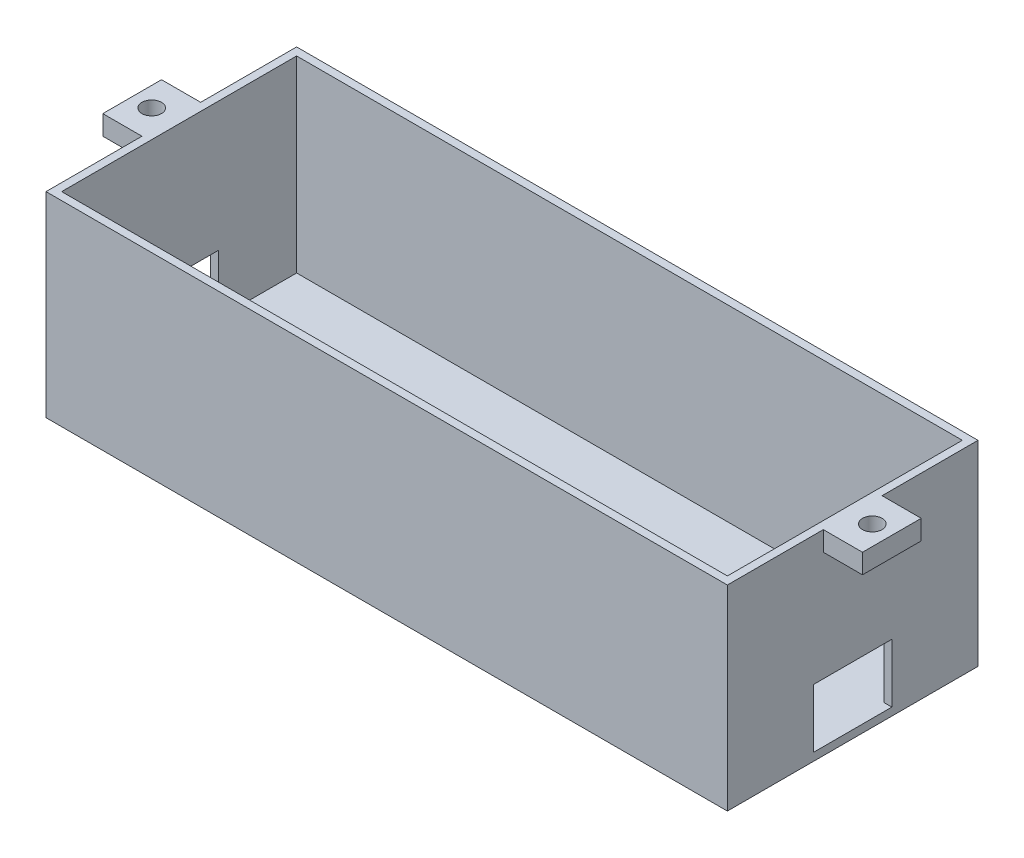
from build123d import *

# Parameters (mm, degrees)
SKETCH1_W           = 174
SKETCH1_H           = 64
SKETCH1_W_2         = 170
SKETCH1_H_2         = 60
BOSS_EXTRUDE1_DEPTH = 25
SKETCH2_W           = 174
SKETCH2_H           = 2
BOSS_EXTRUDE2_DEPTH = 64
SKETCH9_W           = 10
SKETCH9_H           = 15
SKETCH9_R           = 2.5
BOSS_EXTRUDE3_DEPTH = 5
SKETCH10_W          = 20
SKETCH10_H          = 15
CUT_EXTRUDE2_DEPTH  = 174
CUT_EXTRUDE3_REACH  = 4
SKETCH11_R          = 2.5
SKETCH11_R_2        = 1.25


with BuildPart() as part:
    # Sketch1 → Boss-Extrude1 (new body, symmetric)
    with BuildSketch(Plane(origin=(0, 0, 0), x_dir=(1, 0, 0), z_dir=(0, 1, 0))):
        Rectangle(SKETCH1_W, SKETCH1_H)
        Rectangle(SKETCH1_W_2, SKETCH1_H_2, mode=Mode.SUBTRACT)
    extrude(amount=BOSS_EXTRUDE1_DEPTH, both=True)

    # Sketch2 → Boss-Extrude2 (add)
    with BuildSketch(Plane(origin=(0, 0, -32), x_dir=(-1, 0, 0), z_dir=(0, 0, -1))):
        with Locations((0, -24)):
            Rectangle(SKETCH2_W, SKETCH2_H)
    extrude(amount=-BOSS_EXTRUDE2_DEPTH)

    # Sketch9 → Boss-Extrude3 (add)
    with BuildSketch(Plane(origin=(0, 25, 0), x_dir=(1, 0, 0), z_dir=(0, 1, 0))):
        with Locations((-92, 0)):
            Rectangle(SKETCH9_W, SKETCH9_H)
        with Locations((-92, 0)):
            Circle(SKETCH9_R, mode=Mode.SUBTRACT)
        with Locations((92, 0)):
            Rectangle(SKETCH9_W, SKETCH9_H)
        with Locations((92, 0)):
            Circle(SKETCH9_R, mode=Mode.SUBTRACT)
    extrude(amount=-BOSS_EXTRUDE3_DEPTH)

    # Sketch10 → Cut-Extrude2 (cut)
    with BuildSketch(Plane.ZY.offset(87)):
        with Locations((0, -15.5)):
            Rectangle(SKETCH10_W, SKETCH10_H)
    extrude(amount=-CUT_EXTRUDE2_DEPTH, mode=Mode.SUBTRACT)

    # Sketch11 → Cut-Extrude3 (cut, up to next)
    with BuildSketch(Plane(origin=(0, -23, 0), x_dir=(1, 0, 0), z_dir=(0, 1, 0)), mode=Mode.PRIVATE) as cut_extrude3_sk1:
        Circle(SKETCH11_R)
    cut_extrude3_tool1 = extrude(cut_extrude3_sk1.sketch, amount=-CUT_EXTRUDE3_REACH, mode=Mode.PRIVATE) & part.part
    add(cut_extrude3_tool1.solids().sort_by_distance((0, -23, 0))[0], mode=Mode.SUBTRACT)
    # Sketch11 → Cut-Extrude3 (cut, up to next)
    with BuildSketch(Plane(origin=(0, -23, 0), x_dir=(1, 0, 0), z_dir=(0, 1, 0)), mode=Mode.PRIVATE) as cut_extrude3_sk2:
        with Locations((-41.5, 14)):
            Circle(SKETCH11_R_2)
    cut_extrude3_tool2 = extrude(cut_extrude3_sk2.sketch, amount=-CUT_EXTRUDE3_REACH, mode=Mode.PRIVATE) & part.part
    add(cut_extrude3_tool2.solids().sort_by_distance((-41.5, -23, -14))[0], mode=Mode.SUBTRACT)
    # Sketch11 → Cut-Extrude3 (cut, up to next)
    with BuildSketch(Plane(origin=(0, -23, 0), x_dir=(1, 0, 0), z_dir=(0, 1, 0)), mode=Mode.PRIVATE) as cut_extrude3_sk3:
        with Locations((-41.5, -14)):
            Circle(SKETCH11_R_2)
    cut_extrude3_tool3 = extrude(cut_extrude3_sk3.sketch, amount=-CUT_EXTRUDE3_REACH, mode=Mode.PRIVATE) & part.part
    add(cut_extrude3_tool3.solids().sort_by_distance((-41.5, -23, 14))[0], mode=Mode.SUBTRACT)


solid = part.part
